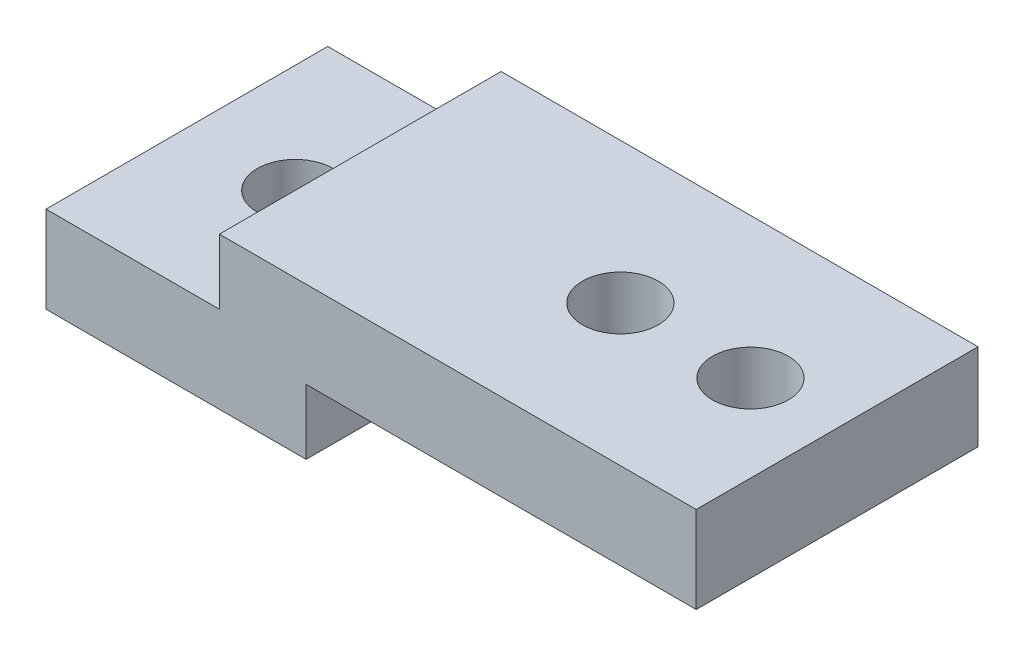
from build123d import *

# Parameters (mm, degrees)
SKETCH1_W           = 30
SKETCH1_H           = 13
BOSS_EXTRUDE1_DEPTH = 4
SKETCH2_W           = 18
SKETCH2_H           = 3
CUT_EXTRUDE1_DEPTH  = 14
SKETCH3_W           = 22
SKETCH3_H           = 13
BOSS_EXTRUDE2_DEPTH = 3
SKETCH4_R           = 1.75
CUT_EXTRUDE2_DEPTH  = 5
SKETCH7_R           = 1.75
CUT_EXTRUDE5_DEPTH  = 8


with BuildPart() as part:
    # Sketch1 → Boss-Extrude1 (new body)
    with BuildSketch(Plane(origin=(0, 0, 0), x_dir=(1, 0, 0), z_dir=(0, 1, 0))):
        with Locations((15, 6.5)):
            Rectangle(SKETCH1_W, SKETCH1_H)
    extrude(amount=BOSS_EXTRUDE1_DEPTH)

    # Sketch2 → Cut-Extrude1 (cut, through all)
    with BuildSketch(Plane.XY):
        with Locations((21, 1.5)):
            Rectangle(SKETCH2_W, SKETCH2_H)
    extrude(amount=-CUT_EXTRUDE1_DEPTH, mode=Mode.SUBTRACT)

    # Sketch3 → Boss-Extrude2 (add)
    with BuildSketch(Plane(origin=(0, 4, 0), x_dir=(1, 0, 0), z_dir=(0, 1, 0))):
        with Locations((19, 6.5)):
            Rectangle(SKETCH3_W, SKETCH3_H)
    extrude(amount=BOSS_EXTRUDE2_DEPTH)

    # Sketch4 → Cut-Extrude2 (cut, through all)
    with BuildSketch(Plane(origin=(0, 4, 0), x_dir=(1, 0, 0), z_dir=(0, 1, 0))):
        with Locations((5, 6.5)):
            Circle(SKETCH4_R)
    extrude(amount=-CUT_EXTRUDE2_DEPTH, mode=Mode.SUBTRACT)

    # Sketch7 → Cut-Extrude5 (cut, through all)
    with BuildSketch(Plane(origin=(0, 7, 0), x_dir=(1, 0, 0), z_dir=(0, 1, 0))):
        with Locations((20, 6.5)):
            Circle(SKETCH7_R)
        with Locations((26, 6.5)):
            Circle(SKETCH7_R)
    extrude(amount=-CUT_EXTRUDE5_DEPTH, mode=Mode.SUBTRACT)


solid = part.part
